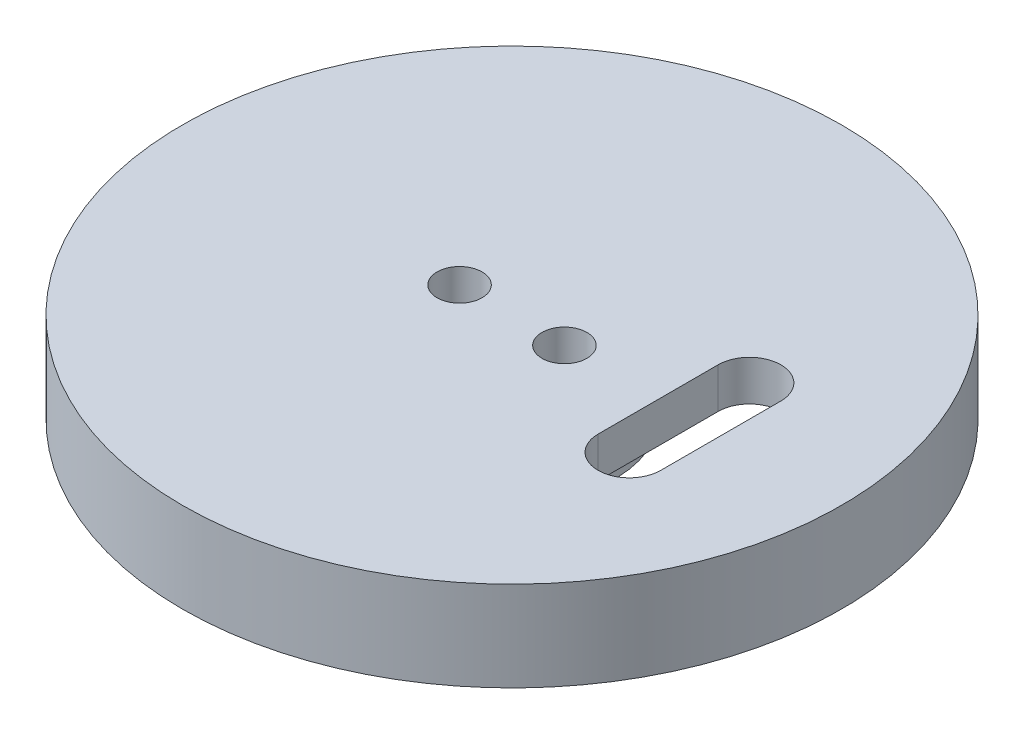
from build123d import *

# Parameters (mm, degrees)
ESQUISSE1_R             = 22
ESQUISSE1_R_2           = 1.5
BOSS_EXTRU_1_DEPTH      = 6
ESQUISSE2_R             = 16.25
ESQUISSE2_R_2           = 6.9
ENL_V_MAT_EXTRU_1_DEPTH = 3.3
ENL_V_MAT_EXTRU_2_DEPTH = 3


with BuildPart() as part:
    # Esquisse1 → Boss.-Extru.1 (new body)
    with BuildSketch(Plane(origin=(0, 0, 0), x_dir=(1, 0, 0), z_dir=(0, 1, 0))):
        Circle(ESQUISSE1_R)
        with Locations((-3.5, 0)):
            Circle(ESQUISSE1_R_2, mode=Mode.SUBTRACT)
        with Locations((3.5, 0)):
            Circle(ESQUISSE1_R_2, mode=Mode.SUBTRACT)
    extrude(amount=BOSS_EXTRU_1_DEPTH)

    # Esquisse2 → Enlèv. mat.-Extru.1 (cut)
    with BuildSketch(Plane.XZ):
        Circle(ESQUISSE2_R)
        Circle(ESQUISSE2_R_2, mode=Mode.SUBTRACT)
    extrude(amount=-ENL_V_MAT_EXTRU_1_DEPTH, mode=Mode.SUBTRACT)

    # Esquisse3 → Enlèv. mat.-Extru.2 (cut)
    with BuildSketch(Plane(origin=(0, 3.3, 0), x_dir=(-1, 0, 0), z_dir=(0, -1, 0))):
        with BuildLine():
            Line((-13.940625792, -4.008679646), (-13.940625792, 4.008679646))
            ThreePointArc((-13.940625792, 4.008679646), (-11.846146155, 6.103159283), (-9.751666518, 4.008679646))
            Line((-9.751666518, 4.008679646), (-9.751666518, -4.008679646))
            ThreePointArc((-9.751666518, -4.008679646), (-11.846146155, -6.103159283), (-13.940625792, -4.008679646))
        make_face()
    extrude(amount=-ENL_V_MAT_EXTRU_2_DEPTH, mode=Mode.SUBTRACT)


solid = part.part
